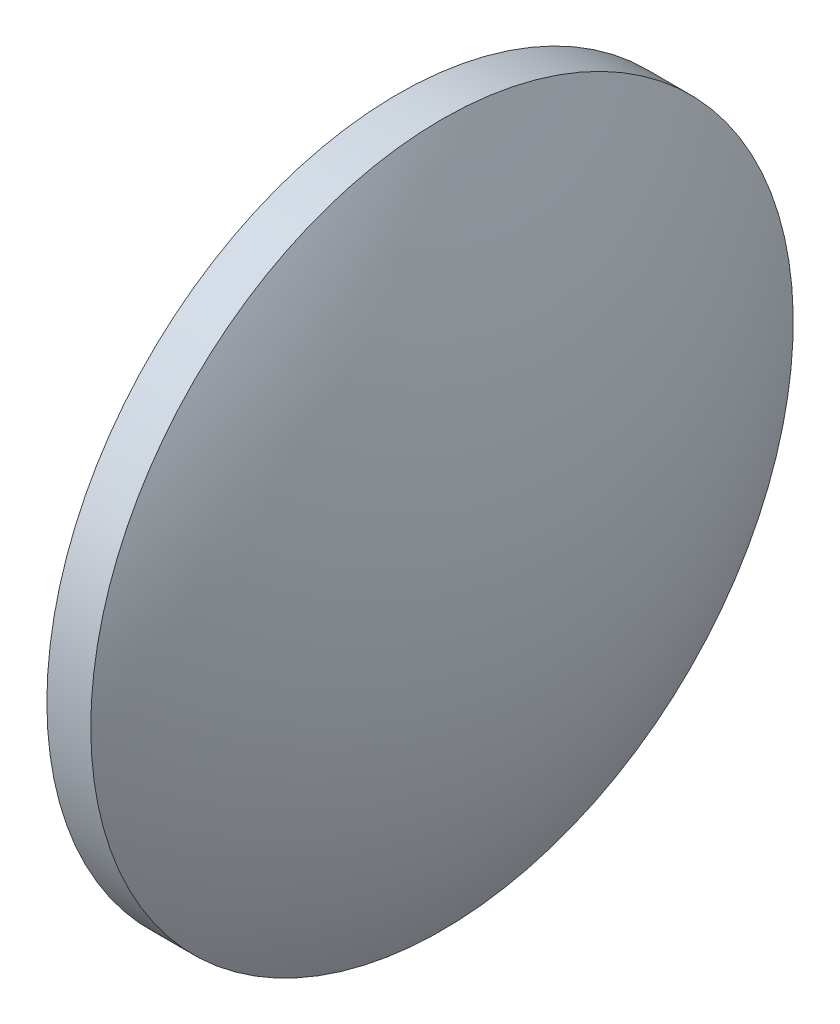
from build123d import *


with BuildPart() as part:
    # 草图2 → 旋转2 (revolve)
    with BuildSketch(Plane.XY):
        with BuildLine():
            Line((447.343689793, 15.686046317), (447.343689793, 35.686046317))
            Line((447.343689793, 35.686046317), (449.843689793, 35.686046317))
            ThreePointArc((449.843689793, 35.686046317), (453.700290478, 26.014755094), (455.013689793, 15.686046317))
            Line((455.013689793, 15.686046317), (447.343689793, 15.686046317))
        make_face()
    revolve(axis=Axis((442.649146613, 15.686046317, 0), (1, 0, 0)))


solid = part.part
